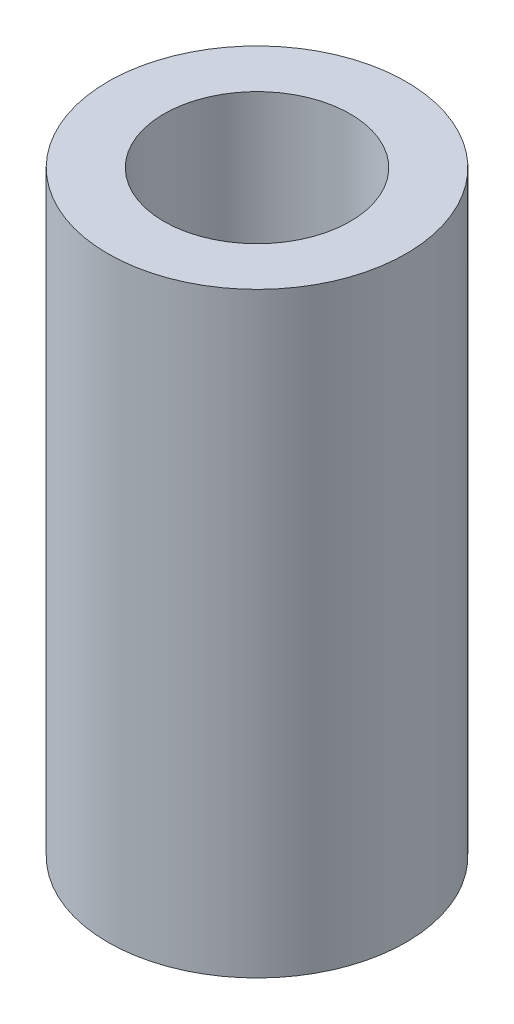
from build123d import *

# Parameters (mm, degrees)
SKETCH1_R           = 8
SKETCH1_R_2         = 5
BOSS_EXTRUDE1_DEPTH = 32


with BuildPart() as part:
    # Sketch1 → Boss-Extrude1 (new body)
    with BuildSketch(Plane(origin=(0, 0, 0), x_dir=(1, 0, 0), z_dir=(0, 1, 0))):
        Circle(SKETCH1_R)
        Circle(SKETCH1_R_2, mode=Mode.SUBTRACT)
    extrude(amount=BOSS_EXTRUDE1_DEPTH)


solid = part.part
